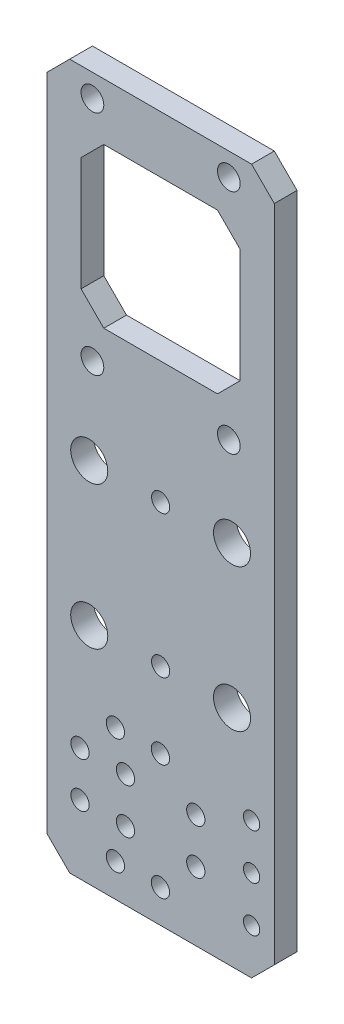
from build123d import *

# Parameters (mm, degrees)
SKETCH1_W                       = 63.5
SKETCH1_H                       = 196.85
BOSS_EXTRUDE1_DEPTH             = 3.175
SKETCH2_R                       = 2.54
SKETCH2_R_2                     = 5.175
CUT_EXTRUDE1_DEPTH              = 119.79762203
SKETCH3_W                       = 44.45
SKETCH3_H                       = 44.45
CUT_EXTRUDE2_DEPTH              = 119.79762203
SKETCH4_R                       = 3.175
CUT_EXTRUDE3_DEPTH              = 119.79762203
CHAMFER1_SIZE                   = 6.35
SKETCH5_R                       = 2.286
CUT_EXTRUDE4_DEPTH              = 119.79762203
F_10_CLEARANCE_HOLE1_AT_2_COUNT = 2
F_10_CLEARANCE_HOLE1_AT_2_PITCH = 13.97
F_10_CLEARANCE_HOLE1_AT_3_COUNT = 2
F_10_CLEARANCE_HOLE1_AT_3_PITCH = 34.687510721
F_10_CLEARANCE_HOLE1_AT_4_COUNT = 2
F_10_CLEARANCE_HOLE1_AT_4_PITCH = 31.75
SKETCH9_R                       = 2.5527
CUT_EXTRUDE6_DEPTH              = 119.79762203


with BuildPart() as part:
    # Sketch1 → Boss-Extrude1 (new, symmetric)
    with BuildSketch(Plane.XY):
        with Locations((0, 15.875)):
            Rectangle(SKETCH1_W, SKETCH1_H)
    extrude(amount=BOSS_EXTRUDE1_DEPTH, both=True)

    # Sketch2 → Cut-Extrude1 (cut, through all)
    with BuildSketch(Plane.XY.offset(3.175)):
        with Locations((0, 19.85)):
            Circle(SKETCH2_R)
        with Locations((0, -19.85)):
            Circle(SKETCH2_R)
        with Locations((-19.939, 19.939)):
            Circle(SKETCH2_R_2)
        with Locations((19.939, 19.939)):
            Circle(SKETCH2_R_2)
        with Locations((19.939, -19.939)):
            Circle(SKETCH2_R_2)
        with Locations((-19.939, -19.939)):
            Circle(SKETCH2_R_2)
    extrude(amount=-CUT_EXTRUDE1_DEPTH, mode=Mode.SUBTRACT)

    # Sketch3 → Cut-Extrude2 (cut, through all)
    with BuildSketch(Plane.XY.offset(3.175)):
        with Locations((0, 76.2)):
            Rectangle(SKETCH3_W, SKETCH3_H)
    extrude(amount=-CUT_EXTRUDE2_DEPTH, mode=Mode.SUBTRACT)

    # Sketch4 → Cut-Extrude3 (cut, through all)
    with BuildSketch(Plane.XY.offset(3.175)):
        with Locations((-19.05, 107.95)):
            Circle(SKETCH4_R)
        with Locations((19.05, 107.95)):
            Circle(SKETCH4_R)
        with Locations((19.05, 44.45)):
            Circle(SKETCH4_R)
        with Locations((-19.05, 44.45)):
            Circle(SKETCH4_R)
    extrude(amount=-CUT_EXTRUDE3_DEPTH, mode=Mode.SUBTRACT)

    # Chamfer1
    chamfer1_edges = [part.edges().sort_by_distance(p)[0] for p in [
        (31.75, -82.55, 0),
        (-31.75, -82.55, 0),
        (31.75, 114.3, 0),
        (-31.75, 114.3, 0),
        (-22.225, 53.975, 0),
        (22.225, 53.975, 0),
        (22.225, 98.425, 0),
        (-22.225, 98.425, 0),
    ]]
    chamfer(chamfer1_edges, length=CHAMFER1_SIZE)

    # Sketch5 → Cut-Extrude4 (cut, through all)
    with BuildSketch(Plane(origin=(0, 0, -3.175), x_dir=(-1, 0, 0), z_dir=(0, 0, -1))):
        with Locations((-25.4, -44.45)):
            Circle(SKETCH5_R)
        with Locations((-25.4, -57.15)):
            Circle(SKETCH5_R)
        with Locations((-25.4, -69.85)):
            Circle(SKETCH5_R)
    extrude(amount=-CUT_EXTRUDE4_DEPTH, mode=Mode.SUBTRACT)

    # Sketch8 → 10 Clearance Hole1 (revolve, cut)
    with BuildSketch(Plane(origin=(-22.514461018, -50.863820715, 3.175), x_dir=(0, -1, 0), z_dir=(1, 0, 0))):
        Polygon((0, 0), (0, 20.583816902), (2.5527, 19.05), (2.5527, 0), align=None)
    f_10_clearance_hole1 = revolve(axis=Axis((-22.514461018, -50.863820715, 9.525), (0, 0, -1)), mode=Mode.SUBTRACT)

    # 10 Clearance Hole1 at 2: 10 Clearance Hole1 ×2
    with Locations(*[Vector(0.7071067811865487, 0.7071067811865465, 0) * (i * F_10_CLEARANCE_HOLE1_AT_2_PITCH) for i in range(1, F_10_CLEARANCE_HOLE1_AT_2_COUNT)]):
        add(f_10_clearance_hole1, mode=Mode.SUBTRACT)

    # 10 Clearance Hole1 at 3: 10 Clearance Hole1 ×2
    with Locations(*[Vector(0.9320046715412955, -0.3624462611549497, 0) * (i * F_10_CLEARANCE_HOLE1_AT_3_PITCH) for i in range(1, F_10_CLEARANCE_HOLE1_AT_3_COUNT)]):
        add(f_10_clearance_hole1, mode=Mode.SUBTRACT)

    # 10 Clearance Hole1 at 4: 10 Clearance Hole1 ×2
    with Locations(*[Vector(0.7071067811865464, -0.7071067811865488, 0) * (i * F_10_CLEARANCE_HOLE1_AT_4_PITCH) for i in range(1, F_10_CLEARANCE_HOLE1_AT_4_COUNT)]):
        add(f_10_clearance_hole1, mode=Mode.SUBTRACT)

    # Mirror1: 10 Clearance Hole1 across plane
    add(f_10_clearance_hole1.mirror(Plane.ZY.offset(6.35)), mode=Mode.SUBTRACT)

    # Mirror1 copy 1 sketch → Mirror1 copy 1 (revolve, cut)
    with BuildSketch(Plane(origin=(-0.063820715, -40.985538982, 3.175), x_dir=(0, -1, 0), z_dir=(-1, 0, 0))):
        Polygon((0, 0), (0, -20.583816902), (2.5527, -19.05), (2.5527, 0), align=None)
    revolve(axis=Axis((-0.063820715, -40.985538982, 9.525), (0, 0, 1)), mode=Mode.SUBTRACT)

    # Mirror1 copy 2 sketch → Mirror1 copy 2 (revolve, cut)
    with BuildSketch(Plane(origin=(-22.514461018, -63.436179285, 3.175), x_dir=(0, -1, 0), z_dir=(-1, 0, 0))):
        Polygon((0, 0), (0, -20.583816902), (2.5527, -19.05), (2.5527, 0), align=None)
    revolve(axis=Axis((-22.514461018, -63.436179285, 9.525), (0, 0, 1)), mode=Mode.SUBTRACT)

    # Mirror1 copy 3 sketch → Mirror1 copy 3 (revolve, cut)
    with BuildSketch(Plane(origin=(-12.636179285, -73.314461018, 3.175), x_dir=(0, -1, 0), z_dir=(-1, 0, 0))):
        Polygon((0, 0), (0, -20.583816902), (2.5527, -19.05), (2.5527, 0), align=None)
    revolve(axis=Axis((-12.636179285, -73.314461018, 9.525), (0, 0, 1)), mode=Mode.SUBTRACT)

    # Sketch9 → Cut-Extrude6 (cut, through all)
    with BuildSketch(Plane.XY.offset(3.175)):
        with Locations((-9.814461018, -50.863820715)):
            Circle(SKETCH9_R)
        with Locations((-9.814461018, -63.436179285)):
            Circle(SKETCH9_R)
    extrude(amount=-CUT_EXTRUDE6_DEPTH, mode=Mode.SUBTRACT)


solid = part.part
